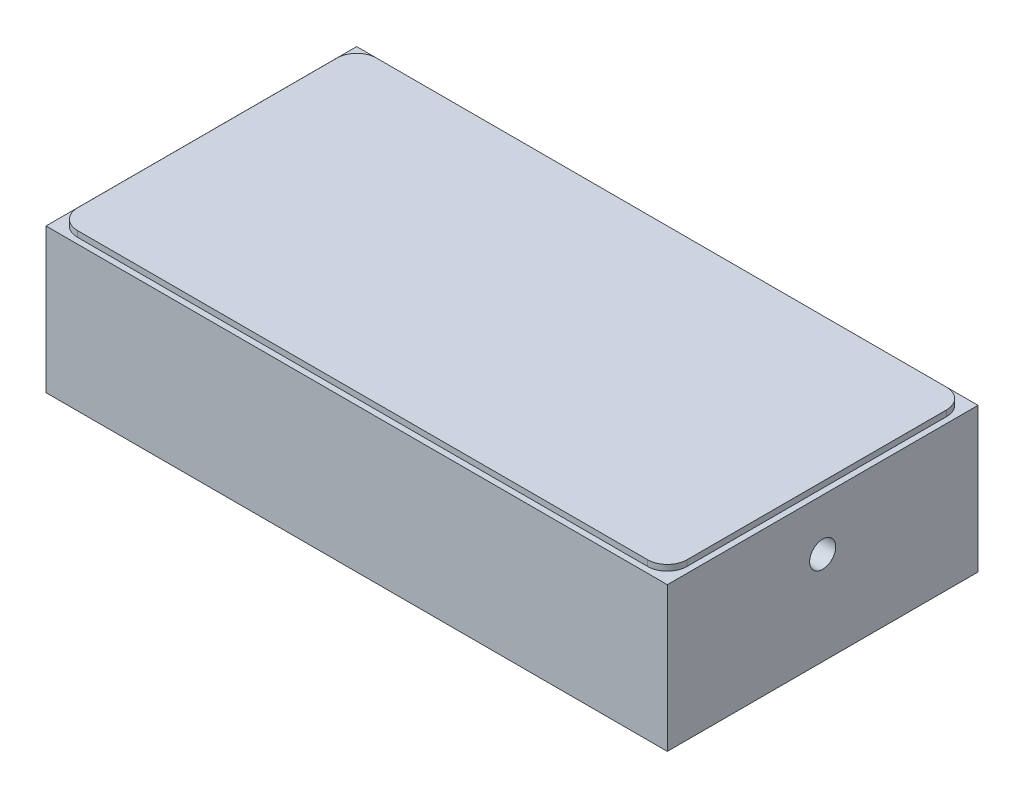
from build123d import *

# Parameters (mm, degrees)
SKETCH1_W                          = 99.9998
SKETCH1_H                          = 50
MAIN_EXTRUDE_DEPTH                 = 24.003
F_1_8_0_125_DIAMETER_HOLE1_D       = 3.175
F_1_8_0_125_DIAMETER_HOLE1_DEPTH   = 5.08
M3X0_5_TAPPED_HOLE1_D              = 2.5
M3X0_5_TAPPED_HOLE1_DEPTH          = 6.35
CIRPATTERN1_COUNT                  = 3
F_3_16_0_1875_DIAMETER_HOLE1_D     = 4.7625
F_3_16_0_1875_DIAMETER_HOLE1_DEPTH = 6.2484
M3X0_5_TAPPED_HOLE2_D              = 2.5
M3X0_5_TAPPED_HOLE2_DEPTH          = 5.801995
M3X0_5_TAPPED_HOLE2_TIP            = 0.751075774
M5X0_8_TAPPED_HOLE2_D              = 4.2
M5X0_8_TAPPED_HOLE2_DEPTH          = 12.7
M5X0_8_TAPPED_HOLE2_TIP            = 1.2618073
M5X0_8_TAPPED_HOLE1_D              = 4.2
CHAMFER1_SIZE                      = 0.762
EXTRUDE1_DEPTH                     = 0.9398
EXTRUDE2_DEPTH                     = 2.49936


with BuildPart() as part:
    # Sketch1 → Main Extrude (new body)
    with BuildSketch(Plane(origin=(0, 0, 0), x_dir=(1, 0, 0), z_dir=(0, 1, 0))):
        Rectangle(SKETCH1_W, SKETCH1_H)
    extrude(amount=MAIN_EXTRUDE_DEPTH)

    # 1_8 _0.125_ Diameter Hole1
    with Locations(Plane.XZ):
        with Locations((-24.9999, 0)):
            Hole(F_1_8_0_125_DIAMETER_HOLE1_D / 2, depth=F_1_8_0_125_DIAMETER_HOLE1_DEPTH)

    # M3x0.5 Tapped Hole1
    with Locations(Plane.XZ):
        with Locations((10.795, 0)):
            m3x0_5_tapped_hole1 = Hole(M3X0_5_TAPPED_HOLE1_D / 2, depth=M3X0_5_TAPPED_HOLE1_DEPTH)

    # CirPattern1: M3x0.5 Tapped Hole1 ×3 about axis
    cirpattern1_axis = Axis((0, 0, 0), (0, 1, 0))
    for i in range(1, CIRPATTERN1_COUNT):
        add(m3x0_5_tapped_hole1.rotate(cirpattern1_axis, i * 360 / CIRPATTERN1_COUNT), mode=Mode.SUBTRACT)

    # 3_16 _0.1875_ Diameter Hole1
    with Locations(Plane.XZ):
        with Locations((0, 0)):
            Hole(F_3_16_0_1875_DIAMETER_HOLE1_D / 2, depth=F_3_16_0_1875_DIAMETER_HOLE1_DEPTH)

    # Sketch12 → Cut-Revolve1 (revolve, cut)
    with BuildSketch(Plane.XZ.offset(0.508)):
        with BuildLine():
            Line((0, 6.5024), (0, -6.5024))
            ThreePointArc((0, -6.5024), (6.5024, 0), (0, 6.5024))
        make_face()
    revolve(axis=Axis((0, -0.508, 6.5024), (0, 0, -1)), mode=Mode.SUBTRACT)

    # M3x0.5 Tapped Hole2
    with Locations(Plane.XZ):
        with Locations((25.0001, 0)):
            Hole(M3X0_5_TAPPED_HOLE2_D / 2, depth=M3X0_5_TAPPED_HOLE2_DEPTH)
            with Locations((0, 0, -(M3X0_5_TAPPED_HOLE2_DEPTH + M3X0_5_TAPPED_HOLE2_TIP / 2))):  # 118° drill point
                Cone(0, M3X0_5_TAPPED_HOLE2_D / 2, M3X0_5_TAPPED_HOLE2_TIP, mode=Mode.SUBTRACT)

    # M5x0.8 Tapped Hole2
    with Locations(Plane(origin=(49.9999, 0, 0), x_dir=(0, 0, -1), z_dir=(1, 0, 0))):
        with Locations((0, 15.748)):
            Hole(M5X0_8_TAPPED_HOLE2_D / 2, depth=M5X0_8_TAPPED_HOLE2_DEPTH)
            with Locations((0, 0, -(M5X0_8_TAPPED_HOLE2_DEPTH + M5X0_8_TAPPED_HOLE2_TIP / 2))):  # 118° drill point
                Cone(0, M5X0_8_TAPPED_HOLE2_D / 2, M5X0_8_TAPPED_HOLE2_TIP, mode=Mode.SUBTRACT)

    # M5x0.8 Tapped Hole1 (through all)
    with Locations(Plane.XZ):
        with Locations((41.3131, 0)):
            Hole(M5X0_8_TAPPED_HOLE1_D / 2)

    # Chamfer1
    chamfer1_edges = [part.edges().sort_by_distance(p)[0] for p in [
        (0, 0, -25),
        (49.9999, 0, 0),
        (0, 0, 25),
        (-49.9999, 0, 0),
    ]]
    chamfer(chamfer1_edges, length=CHAMFER1_SIZE)

    # Sketch2 → Extrude1 (add)
    with BuildSketch(Plane(origin=(0, 24.003, 0), x_dir=(-1, 0, 0), z_dir=(0, 1, 0))):
        with BuildLine():
            Line((45.8724, 24.0475), (-45.8724, 24.0475))
            ThreePointArc((-45.8724, 24.0475), (-48.11746403, 23.11756403), (-49.0474, 20.8725))
            Line((-49.0474, 20.8725), (-49.0474, -20.8851))
            ThreePointArc((-49.0474, -20.8851), (-48.11746403, -23.13016403), (-45.8724, -24.0601))
            Line((-45.8724, -24.0601), (45.8724, -24.0601))
            ThreePointArc((45.8724, -24.0601), (48.11746403, -23.13016403), (49.0474, -20.8851))
            Line((49.0474, -20.8851), (49.0474, 20.8725))
            ThreePointArc((49.0474, 20.8725), (48.11746403, 23.11756403), (45.8724, 24.0475))
        make_face()
    extrude(amount=EXTRUDE1_DEPTH)

    # Sketch19 → Extrude2 (add)
    with BuildSketch(Plane.XZ):
        Polygon((36.693720496, 0), (39.003410248, -4.0005), (43.622789752, -4.0005), (45.932479504, 0), (43.622789752, 4.0005), (39.003410248, 4.0005), align=None)
    extrude(amount=EXTRUDE2_DEPTH)


solid = part.part
